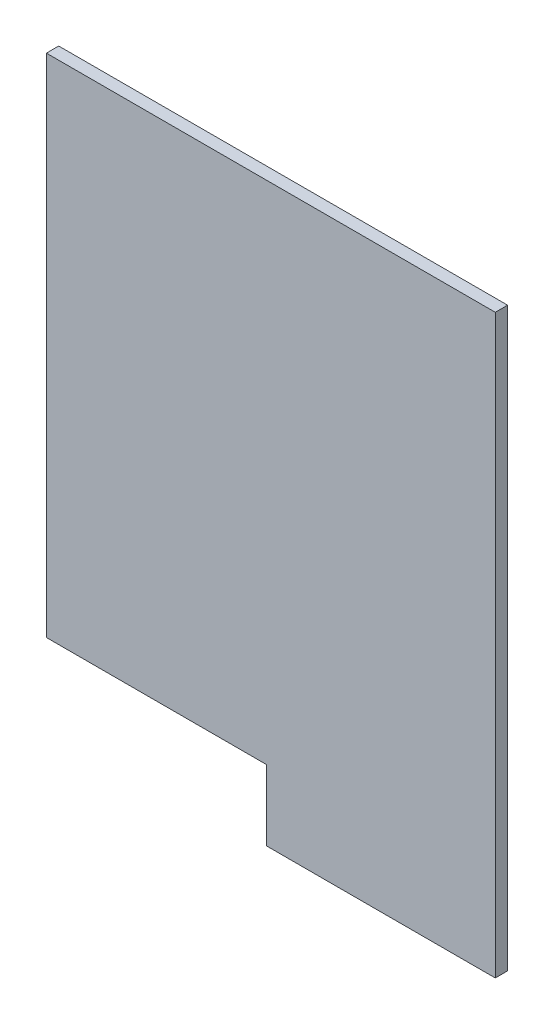
from build123d import *

# Parameters (mm, degrees)
RESSALTO_EXTRUS_O1_DEPTH = 140


with BuildPart() as part:
    # Esboço1 → Ressalto-extrusão1 (new body)
    with BuildSketch(Plane.XY):
        Polygon((0, 0), (0, -5750), (2500, -5750), (2500, -6550), (5100, -6550), (5100, 0), align=None)
    extrude(amount=RESSALTO_EXTRUS_O1_DEPTH)


solid = part.part
